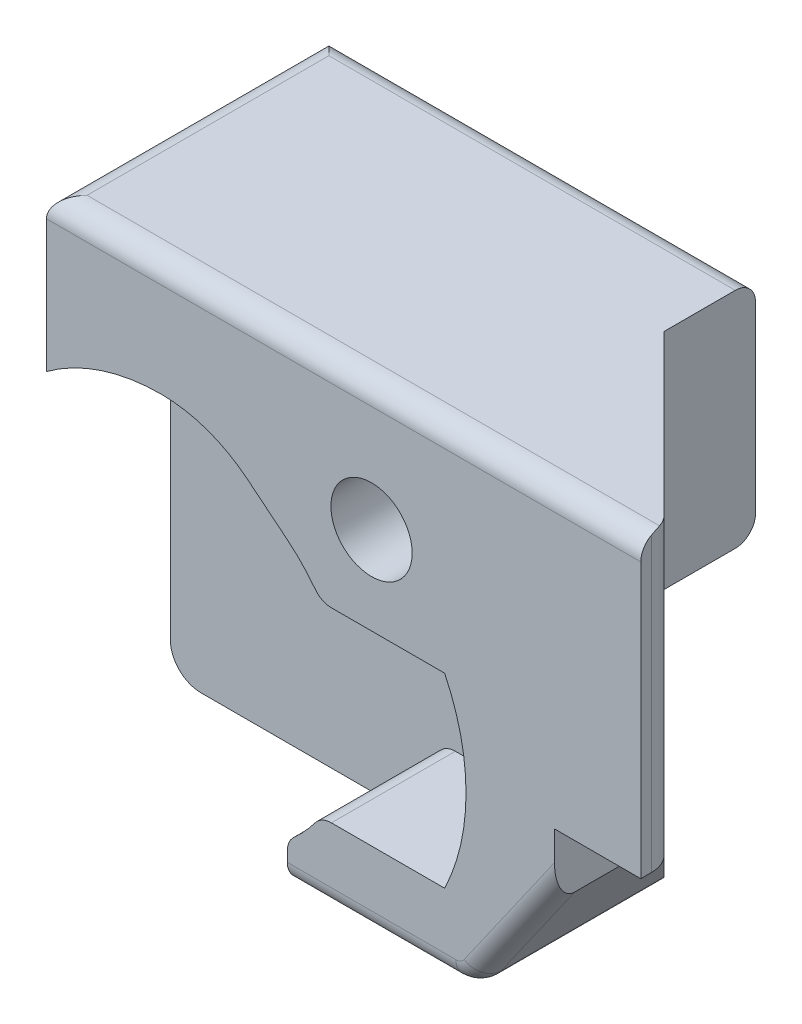
from build123d import *

# Parameters (mm, degrees)
EXTRUDE1_DEPTH  = 4.7752
EXTRUDE2_DEPTH  = 12.938
SKETCH33_W      = 2.286
SKETCH33_H      = 5.588
EXTRUDE30_DEPTH = 10.668
EXTRUDE3_DEPTH  = 3.0988
EXTRUDE6_DEPTH  = 3.0988
EXTRUDE7_DEPTH  = 3.0988
SKETCH23_W      = 3.0988
SKETCH23_H      = 1.133450424
EXTRUDE20_DEPTH = 2.54
EXTRUDE16_DEPTH = 3.0988
FILLET1_R       = 0.762
EXTRUDE21_DEPTH = 3.0988
FILLET2_R       = 0.762
EXTRUDE28_DEPTH = 8.0612
EXTRUDE29_REACH = 9.061
FILLET3_R       = 0.762
FILLET4_R       = 0.508
FILLET5_R       = 0.508
FILLET6_R       = 0.508
SKETCH35_R      = 1.016
EXTRUDE32_DEPTH = 8.0612


with BuildPart() as part:
    # Sketch1 → Extrude1 (new body)
    with BuildSketch(Plane.XY):
        Polygon((-14.859, 11.938), (0, 11.938), (0, 4.572), (-3.175, 4.572), (-3.175, 0), (-14.859, 0), align=None)
    extrude(amount=-EXTRUDE1_DEPTH)

    # Sketch2 → Extrude2 (cut, through all)
    with BuildSketch(Plane(origin=(0, 11.938, 0), x_dir=(1, 0, 0), z_dir=(0, 1, 0))):
        Polygon((0, 0.5842), (-4.191, 4.7752), (0, 4.7752), align=None)
    extrude(amount=-EXTRUDE2_DEPTH, mode=Mode.SUBTRACT)

    # Sketch33 → Extrude30 (add)
    with BuildSketch(Plane.ZY.offset(14.859)):
        with Locations((-5.9182, 9.144)):
            Rectangle(SKETCH33_W, SKETCH33_H)
    extrude(amount=-EXTRUDE30_DEPTH)

    # Sketch5 → Extrude3 (cut)
    with BuildSketch(Plane.XY):
        with BuildLine():
            Line((-14.859, 8.121520088), (-14.859, 0))
            Line((-14.859, 0), (-8.374207602, 0))
            ThreePointArc((-8.374207602, 0), (-5.258197931, 4.182323512), (-8.261178378, 8.44652973))
            ThreePointArc((-8.261178378, 8.44652973), (-10.099280239, 8.911418564), (-11.9888, 9.0678))
            ThreePointArc((-11.9888, 9.0678), (-13.499883528, 8.825128765), (-14.859, 8.121520088))
        make_face()
    extrude(amount=-EXTRUDE3_DEPTH, mode=Mode.SUBTRACT)

    # Sketch8 → Extrude6 (add)
    with BuildSketch(Plane.XY):
        with BuildLine():
            Line((-5.916117419, 6.569687461), (-7.995771884, 6.569687461))
            ThreePointArc((-7.995771884, 6.569687461), (-8.381805974, 7.063274265), (-8.837117419, 7.493787609))
            Line((-8.837117419, 7.493787609), (-8.837117419, 8.601687461))
            ThreePointArc((-8.837117419, 8.601687461), (-7.16441835, 7.890723622), (-5.916117419, 6.569687461))
        make_face()
    extrude(amount=-EXTRUDE6_DEPTH)

    # Sketch9 → Extrude7 (add)
    with BuildSketch(Plane.XY):
        with BuildLine():
            Line((-5.916117419, 1.913912539), (-7.995771884, 1.913912539))
            ThreePointArc((-7.995771884, 1.913912539), (-8.381805974, 1.420325735), (-8.837117419, 0.989812391))
            Line((-8.837117419, 0.989812391), (-8.837117419, 0))
            Line((-8.837117419, 0), (-8.374207602, 0))
            ThreePointArc((-8.374207602, 0), (-6.971998867, 0.734557469), (-5.916117419, 1.913912539))
        make_face()
    extrude(amount=-EXTRUDE7_DEPTH)

    # Sketch23 → Extrude20 (add)
    with BuildSketch(Plane.ZY.offset(8.837117419)):
        with Locations((-1.5494, 8.060512821)):
            Rectangle(SKETCH23_W, SKETCH23_H)
    extrude(amount=-EXTRUDE20_DEPTH)

    # Sketch18 → Extrude16 (cut)
    with BuildSketch(Plane.XY):
        with BuildLine():
            Line((-4.903581733, 6.569687461), (-5.916117419, 6.569687461))
            ThreePointArc((-5.916117419, 6.569687461), (-5.2578, 4.2418), (-5.916117419, 1.913912539))
            Line((-5.916117419, 1.913912539), (-4.903581733, 1.913912539))
            ThreePointArc((-4.903581733, 1.913912539), (-4.3688, 4.2418), (-4.903581733, 6.569687461))
        make_face()
    extrude(amount=-EXTRUDE16_DEPTH, mode=Mode.SUBTRACT)

    # Fillet1
    fillet1_edges = [part.edges().sort_by_distance(p)[0] for p in [
        (0, 8.255, -0.5842),
    ]]
    fillet(fillet1_edges, radius=FILLET1_R)

    # Sketch24 → Extrude21 (add)
    with BuildSketch(Plane.XY):
        with BuildLine():
            Line((-8.837117419, 7.493787609), (-9.830149409, 8.301066631))
            ThreePointArc((-9.830149409, 8.301066631), (-10.843412246, 8.870424655), (-11.9888, 9.0678))
            Line((-11.9888, 9.0678), (-8.837117419, 9.0678))
            Line((-8.837117419, 9.0678), (-8.837117419, 7.493787609))
        make_face()
    extrude(amount=-EXTRUDE21_DEPTH)

    # Fillet2
    fillet2_edges = [part.edges().sort_by_distance(p)[0] for p in [
        (-14.859, 0, -3.937),
    ]]
    fillet(fillet2_edges, radius=FILLET2_R)

    # Sketch31 → Extrude28 (cut, through all)
    with BuildSketch(Plane.XY):
        Polygon((-3.175, 1.499352844), (-4.224858164, 0), (-3.175, 0), align=None)
    extrude(amount=-EXTRUDE28_DEPTH, mode=Mode.SUBTRACT)

    # Extrude29: up to this face of the body (flat: up to its plane)
    extrude29_end = Plane(part.part.faces().sort_by_distance((-2.383005057, 7.601249614, -2.967205057))[0])
    # Sketch32 → Extrude29 (add, up to the picked face)
    with BuildSketch(Plane.XY, mode=Mode.PRIVATE) as extrude29_sk1:
        Polygon((-3.175, 1.499352844), (-2.159, 2.950351219), (-2.159, 4.572), (-3.175, 4.572), align=None)
    extrude29_tool1 = split(extrude(extrude29_sk1.sketch, amount=-EXTRUDE29_REACH, mode=Mode.PRIVATE), bisect_by=extrude29_end, keep=Keep.BOTH, mode=Mode.PRIVATE)
    add(extrude29_tool1.solids().sort_by_distance((-2.719341, 3.361051, 0))[0])

    # Fillet3
    fillet3_edges = [part.edges().sort_by_distance(p)[0] for p in [
        (-4.224858164, 0, -2.3876),
    ]]
    fillet(fillet3_edges, radius=FILLET3_R)

    # Fillet4
    fillet4_edges = [part.edges().sort_by_distance(p)[0] for p in [
        (-3.078168199, 1.637642987, 0),
        (-4.269677813, 0.086097745, 0),
        (-6.729323838, 0, 0),
    ]]
    fillet(fillet4_edges, radius=FILLET4_R)

    # Fillet5
    fillet5_edges = [part.edges().sort_by_distance(p)[0] for p in [
        (-9.525, 11.938, -7.0612),
        (-9.525, 6.35, -7.0612),
        (-7.4295, 11.938, 0),
        (-14.859, 11.938, -3.5306),
    ]]
    fillet(fillet5_edges, radius=FILLET5_R)

    # Fillet6
    fillet6_edges = [part.edges().sort_by_distance(p)[0] for p in [
        (-7.995771884, 6.569687461, -1.5494),
        (-8.837117419, 0.989812391, -1.5494),
        (-7.995771884, 1.913912539, -1.5494),
    ]]
    fillet(fillet6_edges, radius=FILLET6_R)

    # Sketch35 → Extrude32 (cut, through all)
    with BuildSketch(Plane.XY):
        with Locations((-6.731, 8.763)):
            Circle(SKETCH35_R)
    extrude(amount=-EXTRUDE32_DEPTH, mode=Mode.SUBTRACT)


solid = part.part
